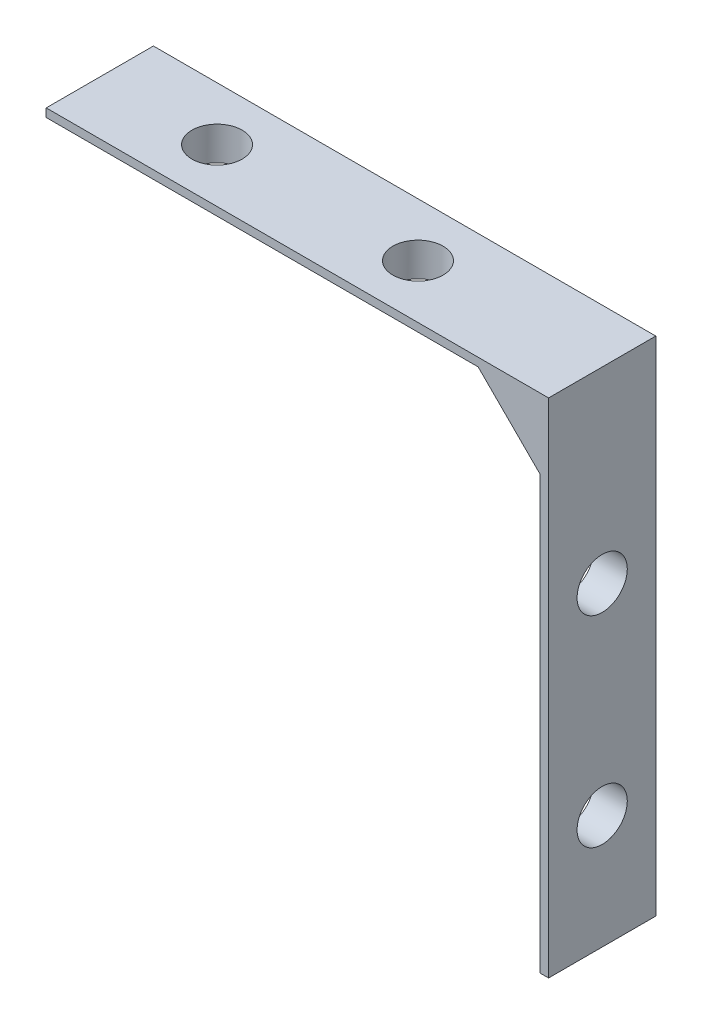
from build123d import *

# Parameters (mm, degrees)
BOSS_EXTRUDE1_DEPTH = 6.4
SKETCH2_R           = 1.5
CUT_EXTRUDE1_DEPTH  = 2
SKETCH3_R           = 1.5
CUT_EXTRUDE2_DEPTH  = 2
CHAMFER9_SIZE       = 1.5
CHAMFER10_SIZE      = 1.5
CHAMFER11_SIZE      = 1.5


with BuildPart() as part:
    # Sketch1 → Boss-Extrude1 (new body)
    with BuildSketch(Plane.XY):
        Polygon((-4.828427125, -2), (-2, -4.828427125), (-2, -30), (0, -30), (0, -2), (0, 0), (-30, 0), (-30, -2), align=None)
    extrude(amount=BOSS_EXTRUDE1_DEPTH)

    # Sketch2 → Cut-Extrude1 (cut)
    with BuildSketch(Plane(origin=(0, 0, 0), x_dir=(1, 0, 0), z_dir=(0, 1, 0))):
        with Locations((-23, -3.2)):
            Circle(SKETCH2_R)
        with Locations((-11, -3.2)):
            Circle(SKETCH2_R)
    extrude(amount=-CUT_EXTRUDE1_DEPTH, mode=Mode.SUBTRACT)

    # Sketch3 → Cut-Extrude2 (cut)
    with BuildSketch(Plane(origin=(0, 0, 0), x_dir=(0, 0, -1), z_dir=(1, 0, 0))):
        with Locations((-3.2, -11.193683163)):
            Circle(SKETCH3_R)
        with Locations((-3.2, -23.193683163)):
            Circle(SKETCH3_R)
    extrude(amount=-CUT_EXTRUDE2_DEPTH, mode=Mode.SUBTRACT)

    # Chamfer9
    chamfer9_edges = [part.edges().sort_by_distance(p)[0] for p in [
        (-17.414213562, -2, 0),
    ]]
    chamfer(chamfer9_edges, length=CHAMFER9_SIZE)

    # Chamfer10
    chamfer10_edges = [part.edges().sort_by_distance(p)[0] for p in [
        (-2, -17.414213562, 0),
        (-3.414213562, -3.414213562, 0),
    ]]
    chamfer(chamfer10_edges, length=CHAMFER10_SIZE)

    # Chamfer11
    chamfer11_edges = [part.edges().sort_by_distance(p)[0] for p in [
        (-17.414213562, -2, 6.4),
        (-3.414213562, -3.414213562, 6.4),
        (-2, -17.414213562, 6.4),
    ]]
    chamfer(chamfer11_edges, length=CHAMFER11_SIZE)


solid = part.part
